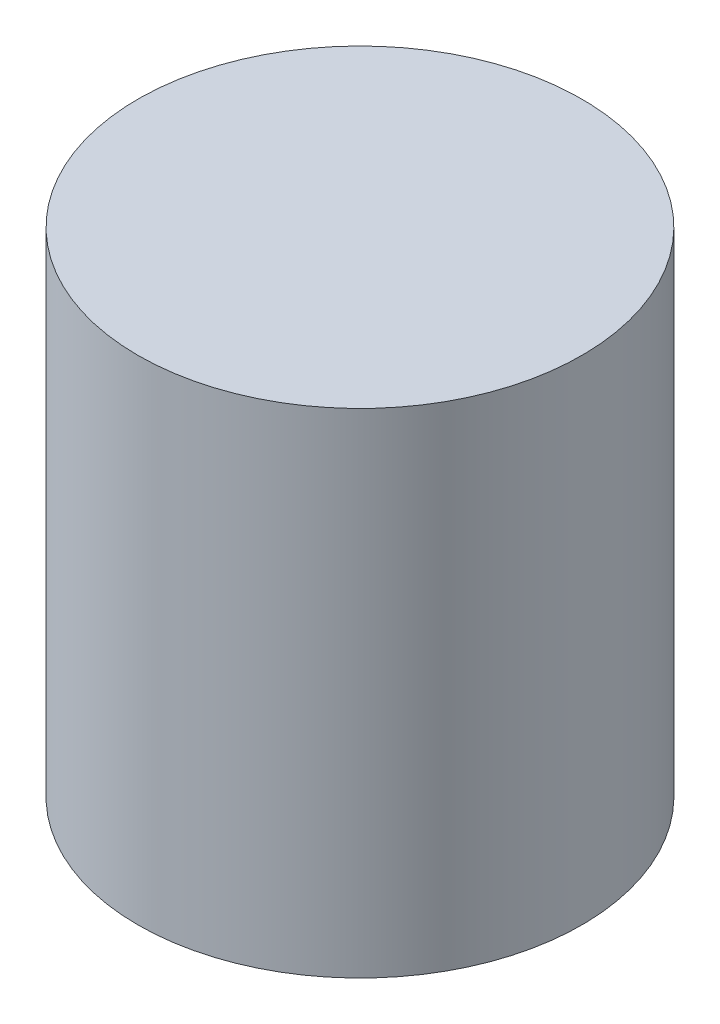
from build123d import *

# Parameters (mm, degrees)
SKETCH1_R           = 45
BOSS_EXTRUDE1_DEPTH = 100


with BuildPart() as part:
    # Sketch1 → Boss-Extrude1 (new body)
    with BuildSketch(Plane(origin=(0, 0, 0), x_dir=(1, 0, 0), z_dir=(0, 1, 0))):
        Circle(SKETCH1_R)
    extrude(amount=BOSS_EXTRUDE1_DEPTH)


solid = part.part
